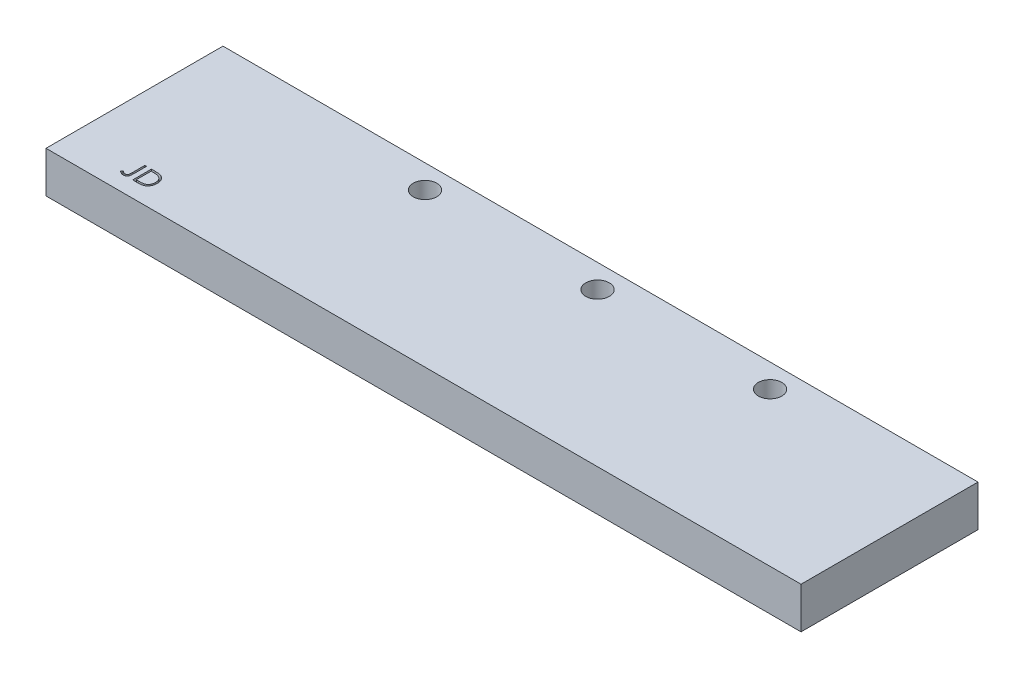
from build123d import *

# Parameters (mm, degrees)
SKETCH1_W           = 128
SKETCH1_H           = 30
BOSS_EXTRUDE1_DEPTH = 7
SKETCH2_R           = 2
CUT_EXTRUDE1_DEPTH  = 10
CUT_EXTRUDE2_DEPTH  = 1


with BuildPart() as part:
    # Sketch1 → Boss-Extrude1 (new body)
    with BuildSketch(Plane(origin=(0, 0, 0), x_dir=(1, 0, 0), z_dir=(0, 1, 0))):
        with Locations((-38.510460251, 50.167364017)):
            Rectangle(SKETCH1_W, SKETCH1_H)
    extrude(amount=BOSS_EXTRUDE1_DEPTH)

    # Sketch2 → Cut-Extrude1 (cut)
    with BuildSketch(Plane.XZ):
        with Locations((-64.260460251, -61.167364017)):
            Circle(SKETCH2_R)
        with Locations((-35.010460251, -61.167364017)):
            Circle(SKETCH2_R)
        with Locations((-5.760460251, -61.167364017)):
            Circle(SKETCH2_R)
    extrude(amount=-CUT_EXTRUDE1_DEPTH, mode=Mode.SUBTRACT)

    # Sketch3 → Cut-Extrude2 (cut)
    with BuildSketch(Plane(origin=(0, 7, 0), x_dir=(1, 0, 0), z_dir=(0, 1, 0))):
        with BuildLine():
            Line((-91.622128911, 41.045104689), (-91.337193013, 41.045104689))
            Line((-91.337193013, 41.045104689), (-91.337193013, 38.901089264))
            add(Edge.make_bspline(
                [(-91.337193013, 38.901089264), (-91.337477782, 38.861442431), (-91.338024574, 38.785315673), (-91.341031218, 38.675665781), (-91.346595158, 38.575543802), (-91.354700491, 38.484722068), (-91.365513845, 38.403485107), (-91.377888206, 38.331205218), (-91.392867674, 38.268485649), (-91.415425111, 38.19805929), (-91.452412907, 38.120821696), (-91.508081578, 38.037405238), (-91.577235614, 37.964440644), (-91.657337266, 37.901074244), (-91.749086623, 37.850585184), (-91.850594294, 37.814340129), (-91.961235412, 37.792232281), (-92.037978983, 37.789897381), (-92.077517533, 37.788694433)],
                knots=[0, 0, 0, 0, 0.000118942, 0.000228383, 0.000329037, 0.000419729, 0.000501854, 0.000574841, 0.000639631, 0.000695143, 0.000796428, 0.00089539, 0.00099483, 0.001096746, 0.001200653, 0.001307483, 0.001418995, 0.001537501, 0.001537501, 0.001537501, 0.001537501], degree=3))
            add(Edge.make_bspline(
                [(-92.077517533, 37.788694433), (-92.108322615, 37.7896747), (-92.17030448, 37.791647061), (-92.26255248, 37.807723187), (-92.354538559, 37.83250274), (-92.446750944, 37.868790809), (-92.54101147, 37.918144459), (-92.638596771, 37.982719257), (-92.740762094, 38.062394999), (-92.808056932, 38.123207811), (-92.843282757, 38.155040587)],
                knots=[0, 0, 0, 0, 9.2363e-05, 0.00018584, 0.000280112, 0.000377788, 0.000482474, 0.000598727, 0.000728365, 0.000870765, 0.000870765, 0.000870765, 0.000870765], degree=3))
            Line((-92.843282757, 38.155040587), (-92.675374103, 38.399271356))
            add(Edge.make_bspline(
                [(-92.675374103, 38.399271356), (-92.636636673, 38.372558361), (-92.563495353, 38.322120743), (-92.455994896, 38.257235898), (-92.360747479, 38.201605212), (-92.298442234, 38.17325493), (-92.269594856, 38.160128728)],
                knots=[0, 0, 0, 0, 0.000141121, 0.000266456, 0.000376665, 0.000471687, 0.000471687, 0.000471687, 0.000471687], degree=3))
            add(Edge.make_bspline(
                [(-92.269594856, 38.160128728), (-92.252101231, 38.15327122), (-92.217792336, 38.13982212), (-92.165336728, 38.124812627), (-92.113180516, 38.116609869), (-92.078602322, 38.11508466), (-92.061617092, 38.114335458)],
                knots=[0, 0, 0, 0, 5.6351e-05, 0.000110517, 0.000163322, 0.000214303, 0.000214303, 0.000214303, 0.000214303], degree=3))
            add(Edge.make_bspline(
                [(-92.061617092, 38.114335458), (-92.039679848, 38.115263225), (-91.996318006, 38.117097078), (-91.93330424, 38.13328892), (-91.873017311, 38.158003486), (-91.817618408, 38.194190588), (-91.766559521, 38.237217663), (-91.724429243, 38.289247756), (-91.689307171, 38.346911185), (-91.668171021, 38.401495289), (-91.654704692, 38.451276232), (-91.646157931, 38.497026291), (-91.638684289, 38.550512775), (-91.632169595, 38.611799528), (-91.62835554, 38.681009251), (-91.624076299, 38.757938723), (-91.622529384, 38.842781901), (-91.622266475, 38.90193755), (-91.622128911, 38.932890146)],
                knots=[0, 0, 0, 0, 6.5707e-05, 0.000129879, 0.000194019, 0.00026036, 0.000327553, 0.000393515, 0.000460269, 0.000529361, 0.000568242, 0.000614893, 0.000668861, 0.000730249, 0.000799717, 0.00087677, 0.000961382, 0.001054243, 0.001054243, 0.001054243, 0.001054243], degree=3))
            Line((-91.622128911, 38.932890146), (-91.622128911, 41.045104689))
        make_face()
        with BuildLine():
            Line((-90.523090449, 37.870104689), (-90.523090449, 41.045104689))
            Line((-90.523090449, 41.045104689), (-89.88198468, 41.045104689))
            add(Edge.make_bspline(
                [(-89.88198468, 41.045104689), (-89.826223526, 41.044703215), (-89.718493268, 41.043927569), (-89.562816262, 41.039009593), (-89.418776706, 41.03030967), (-89.286848327, 41.017637314), (-89.166668942, 41.002077062), (-89.058575061, 40.982573124), (-88.96200776, 40.959542427), (-88.902617625, 40.939906911), (-88.874532757, 40.930621516)],
                knots=[0, 0, 0, 0, 0.000167284, 0.000323191, 0.000467206, 0.000600108, 0.000720732, 0.000830638, 0.000929518, 0.001018226, 0.001018226, 0.001018226, 0.001018226], degree=3))
            add(Edge.make_bspline(
                [(-88.874532757, 40.930621516), (-88.837798243, 40.916623662), (-88.765162233, 40.888945378), (-88.661741486, 40.83673359), (-88.56438205, 40.777575991), (-88.472561826, 40.711394601), (-88.388378219, 40.636315513), (-88.308542484, 40.555528014), (-88.236320556, 40.466094306), (-88.170182316, 40.369869138), (-88.110550682, 40.267986062), (-88.058717303, 40.160639213), (-88.015669752, 40.048373746), (-87.979934468, 39.931501862), (-87.951770896, 39.809766576), (-87.932555858, 39.683026141), (-87.919882174, 39.551781447), (-87.918608499, 39.462723184), (-87.917962244, 39.417535579)],
                knots=[0, 0, 0, 0, 0.000117869, 0.000233066, 0.000346943, 0.000459403, 0.000572066, 0.000684957, 0.000799786, 0.0009164, 0.001034974, 0.001153596, 0.001273599, 0.001395318, 0.001519979, 0.001648073, 0.001779649, 0.001915175, 0.001915175, 0.001915175, 0.001915175], degree=3))
            add(Edge.make_bspline(
                [(-87.917962244, 39.417535579), (-87.918532808, 39.378291455), (-87.919657162, 39.300956811), (-87.929753042, 39.18698257), (-87.944427275, 39.076389544), (-87.96714594, 38.969704374), (-87.994725363, 38.865992347), (-88.030071414, 38.766358811), (-88.070562186, 38.669889784), (-88.117778861, 38.577889646), (-88.169614261, 38.490728301), (-88.225241842, 38.408563357), (-88.284602273, 38.332567263), (-88.348261597, 38.262509879), (-88.415397168, 38.198496819), (-88.486448525, 38.139993348), (-88.561599007, 38.088144188), (-88.64051202, 38.040911882), (-88.725489651, 37.999709131), (-88.818141473, 37.964847622), (-88.918862613, 37.935958193), (-89.027405845, 37.911854594), (-89.143958714, 37.89273447), (-89.268635491, 37.879919814), (-89.401244618, 37.871253939), (-89.492302951, 37.870495211), (-89.539171178, 37.870104689)],
                knots=[0, 0, 0, 0, 0.000117706, 0.000231952, 0.000343037, 0.000452182, 0.00055895, 0.000664755, 0.000769064, 0.000872602, 0.000974698, 0.001073133, 0.001170083, 0.001263736, 0.001356857, 0.001448148, 0.00153954, 0.00163051, 0.001723812, 0.001822446, 0.001927109, 0.0020379, 0.002155845, 0.002281218, 0.002413768, 0.002554351, 0.002554351, 0.002554351, 0.002554351], degree=3))
            Line((-89.539171178, 37.870104689), (-90.523090449, 37.870104689))
        make_face()
        with BuildLine():
            Line((-90.238154552, 38.195745715), (-89.873716451, 38.195745715))
            add(Edge.make_bspline(
                [(-89.873716451, 38.195745715), (-89.821348572, 38.195970774), (-89.720625962, 38.196403644), (-89.57579335, 38.200202036), (-89.443459897, 38.20640865), (-89.323606814, 38.215094614), (-89.21630177, 38.226586858), (-89.121320512, 38.239400162), (-89.038974384, 38.255363564), (-88.989145538, 38.269833363), (-88.966119295, 38.276519954)],
                knots=[0, 0, 0, 0, 0.000157102, 0.000302164, 0.000434608, 0.000554511, 0.000662606, 0.000758309, 0.000842005, 0.000913909, 0.000913909, 0.000913909, 0.000913909], degree=3))
            add(Edge.make_bspline(
                [(-88.966119295, 38.276519954), (-88.937137567, 38.286726724), (-88.879866338, 38.306896477), (-88.797424211, 38.34368807), (-88.720537499, 38.38726909), (-88.647866262, 38.435712582), (-88.580441368, 38.490727169), (-88.517463776, 38.551116566), (-88.459060285, 38.617188112), (-88.405834306, 38.688859802), (-88.358201773, 38.765685545), (-88.316952872, 38.846910058), (-88.28080184, 38.931643379), (-88.252427688, 39.021186687), (-88.230188551, 39.114739476), (-88.214436298, 39.212308326), (-88.204625798, 39.313875018), (-88.203481484, 39.382955873), (-88.202898142, 39.418171596)],
                knots=[0, 0, 0, 0, 9.2159e-05, 0.000182117, 0.000270395, 0.000357008, 0.000443824, 0.00053109, 0.000618505, 0.000708057, 0.0007986, 0.000889339, 0.000981122, 0.001074651, 0.001170759, 0.00126936, 0.001370936, 0.001476563, 0.001476563, 0.001476563, 0.001476563], degree=3))
            add(Edge.make_bspline(
                [(-88.202898142, 39.418171596), (-88.203363767, 39.45530411), (-88.204278491, 39.528251263), (-88.215775901, 39.63528568), (-88.232577598, 39.738228841), (-88.256874227, 39.837087633), (-88.28783581, 39.932054924), (-88.326475235, 40.02260548), (-88.370622811, 40.109695611), (-88.42314941, 40.191315214), (-88.480676412, 40.26850682), (-88.544519203, 40.339223065), (-88.613663481, 40.403625037), (-88.687355094, 40.462715699), (-88.767670891, 40.514117748), (-88.852718882, 40.560097809), (-88.943746741, 40.599119367), (-89.007076829, 40.619873764), (-89.039261323, 40.630421196)],
                knots=[0, 0, 0, 0, 0.000111349, 0.000218745, 0.000322574, 0.000424076, 0.000523836, 0.000621881, 0.000719165, 0.000816384, 0.000912677, 0.0010077, 0.001101747, 0.001195912, 0.001290646, 0.001387396, 0.001485691, 0.001587265, 0.001587265, 0.001587265, 0.001587265], degree=3))
            add(Edge.make_bspline(
                [(-89.039261323, 40.630421196), (-89.065887005, 40.637783955), (-89.122500512, 40.653439202), (-89.214883455, 40.670516504), (-89.318855769, 40.685579157), (-89.434879069, 40.698331807), (-89.5628211, 40.707482448), (-89.70278026, 40.714350712), (-89.854817044, 40.718983158), (-89.9602112, 40.719299485), (-90.014912364, 40.719463664)],
                knots=[0, 0, 0, 0, 8.2841e-05, 0.000176143, 0.000281561, 0.000398013, 0.000526208, 0.000666307, 0.00081838, 0.000982477, 0.000982477, 0.000982477, 0.000982477], degree=3))
            Line((-90.014912364, 40.719463664), (-90.238154552, 40.719463664))
            Line((-90.238154552, 40.719463664), (-90.238154552, 38.195745715))
        make_face(mode=Mode.SUBTRACT)
    extrude(amount=-CUT_EXTRUDE2_DEPTH, mode=Mode.SUBTRACT)


solid = part.part
